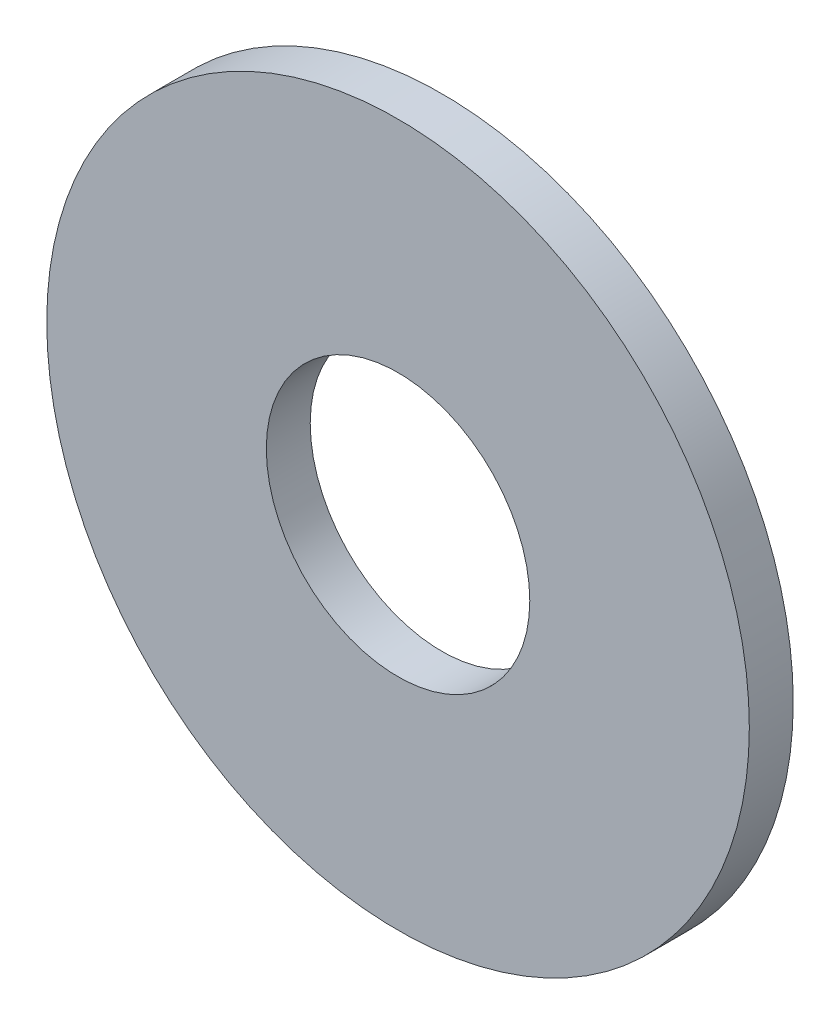
from build123d import *

# Parameters (mm, degrees)
SKETCH1_R           = 8
SKETCH1_R_2         = 3
BOSS_EXTRUDE1_DEPTH = 1


with BuildPart() as part:
    # Sketch1 → Boss-Extrude1 (new body)
    with BuildSketch(Plane.XY):
        Circle(SKETCH1_R)
        Circle(SKETCH1_R_2, mode=Mode.SUBTRACT)
    extrude(amount=BOSS_EXTRUDE1_DEPTH)


solid = part.part
